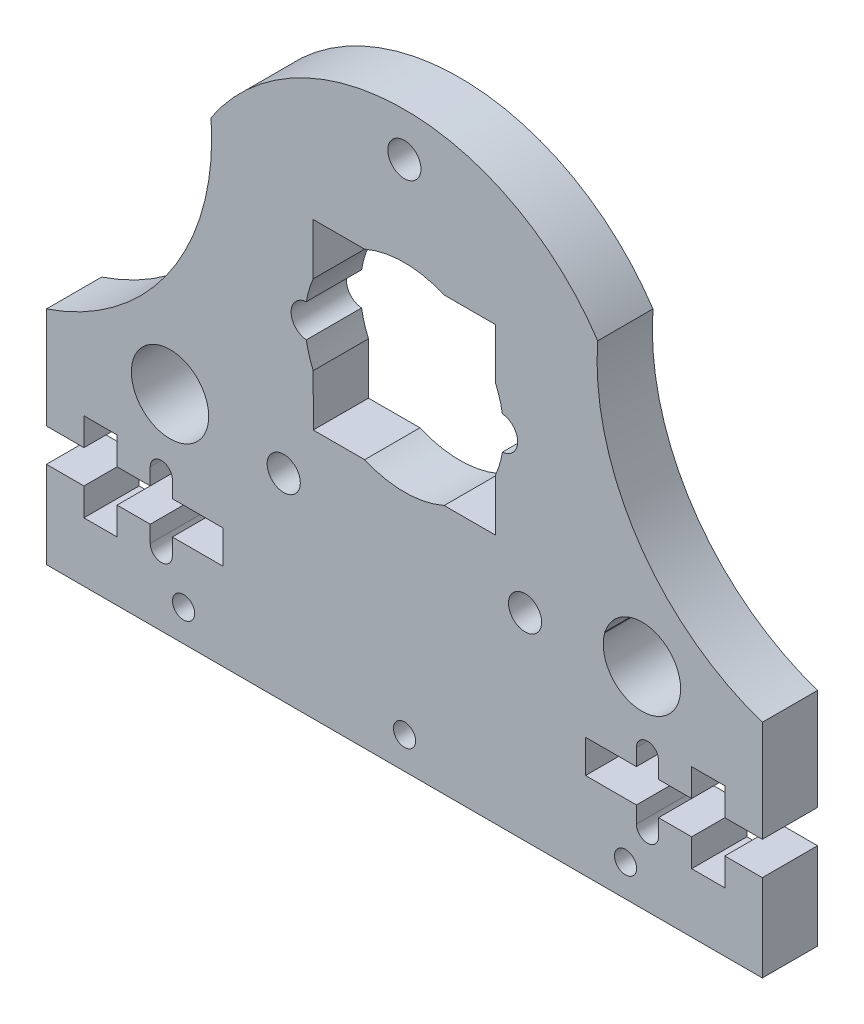
from build123d import *

# Parameters (mm, degrees)
SKETCH1_R           = 3.5
SKETCH1_R_2         = 1.5
BOSS_EXTRUDE1_DEPTH = 5
SKETCH2_W           = 3
SKETCH2_H           = 8
SKETCH2_W_2         = 16
SKETCH2_H_2         = 3
CUT_EXTRUDE3_DEPTH  = 10
SKETCH4_OUTSIDE_W   = 83.878
SKETCH4_OUTSIDE_H   = 74.539
CUT_EXTRUDE5_DEPTH  = 10
BOSS_EXTRUDE2_DEPTH = 5
SKETCH5_R           = 1
CUT_EXTRUDE6_DEPTH  = 5
CUT_EXTRUDE7_DEPTH  = 46.035343011


with BuildPart() as part:
    # Sketch1 → Boss-Extrude1 (new body)
    with BuildSketch(Plane.XY):
        with BuildLine():
            Line((16.678684739, -6.865443356), (7.048954955, 19.63254949))
            ThreePointArc((7.048954955, 19.63254949), (-0.000574134, 24.570863688), (-7.049347073, 19.631470247))
            Line((-7.049347073, 19.631470247), (-16.60248251, -6.668301445))
            ThreePointArc((-16.60248251, -6.668301445), (-23.589225287, -5.352701736), (-28.111762071, -10.838322782))
            Line((-28.111762071, -10.838322782), (-32.396038203, -10.838322782))
            Line((-32.396038203, -10.838322782), (-32.396038203, -30.881690835))
            Line((-32.396038203, -30.881690835), (32.396038203, -30.881690835))
            Line((32.396038203, -30.881690835), (32.396038203, -10.838322782))
            Line((32.396038203, -10.838322782), (28.403544795, -10.838322782))
            ThreePointArc((28.403544795, -10.838322782), (23.74315896, -5.304380506), (16.678684739, -6.865443356))
        make_face()
        with Locations((-21.209007359, -11.922115015)):
            Circle(SKETCH1_R, mode=Mode.SUBTRACT)
        with BuildLine():
            Line((3.592595297, 8.251863973), (8.245757774, 8.254276772))
            Line((8.245757774, 8.254276772), (8.248133809, 3.67201473))
            ThreePointArc((8.248133809, 3.67201473), (8.625435504, 2.640272663), (8.874223719, 1.570248043))
            ThreePointArc((8.874223719, 1.570248043), (10.249998622, 0.076178628), (8.875773895, -1.41931674))
            ThreePointArc((8.875773895, -1.41931674), (8.62809549, -2.489598792), (8.251863973, -3.521731588))
            Line((8.251863973, -3.521731588), (8.254313497, -8.24572101))
            Line((8.254313497, -8.24572101), (3.601151021, -8.248133809))
            ThreePointArc((3.601151021, -8.248133809), (0.004666758, -8.99999879), (-3.592595297, -8.251863973))
            Line((-3.592595297, -8.251863973), (-8.245721029, -8.254276752))
            Line((-8.245721029, -8.254276752), (-8.248133809, -3.601151021))
            ThreePointArc((-8.248133809, -3.601151021), (-8.625435504, -2.569408953), (-8.874223719, -1.499384334))
            ThreePointArc((-8.874223719, -1.499384334), (-10.249998622, -0.005314919), (-8.875773895, 1.49018045))
            ThreePointArc((-8.875773895, 1.49018045), (-8.62809549, 2.560462502), (-8.251863973, 3.592595297))
            Line((-8.251863973, 3.592595297), (-8.254276752, 8.245721029))
            Line((-8.254276752, 8.245721029), (-3.601151021, 8.248133809))
            ThreePointArc((-3.601151021, 8.248133809), (-0.004666758, 8.99999879), (3.592595297, 8.251863973))
        make_face(mode=Mode.SUBTRACT)
        with Locations((0, 17.070863709)):
            Circle(SKETCH1_R_2, mode=Mode.SUBTRACT)
        with BuildLine():
            ThreePointArc((18.172818569, -10.838322782), (24.845541744, -12.952957548), (18.140100673, -10.944481806))
            ThreePointArc((18.140100673, -10.944481806), (18.124834746, -10.891345307), (18.109177542, -10.838322782))
            Line((18.109177542, -10.838322782), (18.172818569, -10.838322782))
        make_face(mode=Mode.SUBTRACT)
        with BuildLine():
            Line((-11.086043951, -20.488849886), (-10.753093745, -20.488849886))
            ThreePointArc((-10.753093745, -20.488849886), (-10.919568848, -20.490697711), (-11.086043951, -20.488849886))
        make_face(mode=Mode.SUBTRACT)
        with Locations((10.924107384, -12.988849886)):
            Circle(SKETCH1_R_2, mode=Mode.SUBTRACT)
        with Locations((-10.919568848, -12.990697711)):
            Circle(SKETCH1_R_2, mode=Mode.SUBTRACT)
    extrude(amount=BOSS_EXTRUDE1_DEPTH)

    # Sketch2 → Cut-Extrude3 (cut)
    with BuildSketch(Plane.XY.offset(5)):
        with Locations((27.500296009, -21.513780425)):
            Rectangle(SKETCH2_W, SKETCH2_H)
        with Locations((24.396038203, -21.513780425)):
            Rectangle(SKETCH2_W_2, SKETCH2_H_2)
        with BuildLine():
            Line((23.000296009, -18.513780425), (23.000296009, -24.513780425))
            ThreePointArc((23.000296009, -24.513780425), (22.000296009, -25.513780425), (21.000296009, -24.513780425))
            Line((21.000296009, -24.513780425), (21.000296009, -18.513780425))
            ThreePointArc((21.000296009, -18.513780425), (22.000296009, -17.513780425), (23.000296009, -18.513780425))
        make_face()
    cut_extrude3 = extrude(amount=-CUT_EXTRUDE3_DEPTH, mode=Mode.SUBTRACT)

    # Mirror1: Cut-Extrude3 across plane
    add(cut_extrude3.mirror(Plane(origin=(0, 0, 0), x_dir=(0, 0, 1), z_dir=(1, 0, 0))), mode=Mode.SUBTRACT)

    # Sketch4 outside → Cut-Extrude5 (cut)
    with BuildSketch(Plane.XY.offset(5)):
        with Locations((0, -3.1555)):
            Rectangle(SKETCH4_OUTSIDE_W, SKETCH4_OUTSIDE_H)
        with BuildLine():
            Line((-28.111762071, -10.838322782), (-32.396038203, -10.838322782))
            Line((-32.396038203, -10.838322782), (-32.396038203, -30.881690835))
            Line((-32.396038203, -30.881690835), (32.396038203, -30.881690835))
            Line((32.396038203, -30.881690835), (32.396038203, -10.838322782))
            Line((32.396038203, -10.838322782), (28.403544795, -10.838322782))
            ThreePointArc((28.403544795, -10.838322782), (23.74315896, -5.304380506), (16.678684739, -6.865443356))
            Line((16.678684739, -6.865443356), (7.048954955, 19.63254949))
            Line((7.048954955, 19.63254949), (6.984017788, 19.804633184))
            ThreePointArc((6.984017788, 19.804633184), (0, 21), (-6.984017788, 19.804633184))
            Line((-6.984017788, 19.804633184), (-7.049347073, 19.631470247))
            Line((-7.049347073, 19.631470247), (-16.60248251, -6.668301445))
            ThreePointArc((-16.60248251, -6.668301445), (-23.589225287, -5.352701736), (-28.111762071, -10.838322782))
        make_face(mode=Mode.SUBTRACT)
    extrude(amount=-CUT_EXTRUDE5_DEPTH, mode=Mode.SUBTRACT)

    # Sketch4_5 → Boss-Extrude2 (add)
    with BuildSketch(Plane.XY.offset(5)):
        with BuildLine():
            Line((-17.497591027, 11.611817612), (-32.396038203, -10.838322782))
            Line((-32.396038203, -10.838322782), (-28.111762071, -10.838322782))
            ThreePointArc((-28.111762071, -10.838322782), (-23.589225287, -5.352701736), (-16.60248251, -6.668301445))
            Line((-16.60248251, -6.668301445), (-7.049347073, 19.631470247))
            Line((-7.049347073, 19.631470247), (-6.984017788, 19.804633184))
            ThreePointArc((-6.984017788, 19.804633184), (-12.90805366, 16.564484619), (-17.497591027, 11.611817612))
        make_face()
        with BuildLine():
            ThreePointArc((17.497591027, 11.611817612), (12.90805366, 16.564484619), (6.984017788, 19.804633184))
            Line((6.984017788, 19.804633184), (7.048954955, 19.63254949))
            Line((7.048954955, 19.63254949), (16.678684739, -6.865443356))
            ThreePointArc((16.678684739, -6.865443356), (23.74315896, -5.304380506), (28.403544795, -10.838322782))
            Line((28.403544795, -10.838322782), (32.396038203, -10.838322782))
            Line((32.396038203, -10.838322782), (17.497591027, 11.611817612))
        make_face()
    extrude(amount=-BOSS_EXTRUDE2_DEPTH)

    # Sketch5 → Cut-Extrude6 (cut)
    with BuildSketch(Plane.XY.offset(5)):
        with Locations((0.014555548, -27.999996217)):
            Circle(SKETCH5_R)
        with Locations((20.014552859, -27.989625643)):
            Circle(SKETCH5_R)
        with Locations((-19.985441764, -28.01036679)):
            Circle(SKETCH5_R)
    extrude(amount=-CUT_EXTRUDE6_DEPTH, mode=Mode.SUBTRACT)

    # Sketch6 → Cut-Extrude7 (cut, through all)
    with BuildSketch(Plane.XY.offset(5)):
        with BuildLine():
            ThreePointArc((-32.396038203, -10.838322782), (-21.107946915, -2.160816504), (-17.497591027, 11.611817612))
            ThreePointArc((-17.497591027, 11.611817612), (-30.842179781, 4.299051969), (-32.396038203, -10.838322782))
        make_face()
        with BuildLine():
            ThreePointArc((32.396038203, -10.838322782), (21.107946915, -2.160816504), (17.497591027, 11.611817612))
            ThreePointArc((17.497591027, 11.611817612), (30.860111099, 4.310951618), (32.396038203, -10.838322782))
        make_face()
    extrude(amount=-CUT_EXTRUDE7_DEPTH, mode=Mode.SUBTRACT)


solid = part.part
